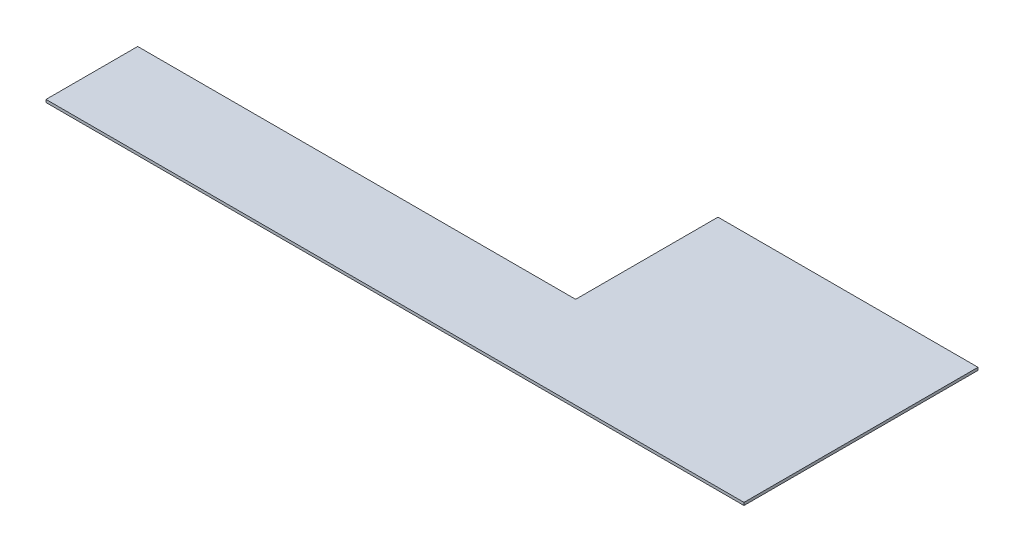
from build123d import *

# Parameters (mm, degrees)
BOSS_EXTRUDE1_DEPTH = 6.35


with BuildPart() as part:
    # Sketch1 → Boss-Extrude1 (new body)
    with BuildSketch(Plane(origin=(0, 0, 0), x_dir=(1, 0, 0), z_dir=(0, 1, 0))):
        Polygon((-1016, 0), (0, 0), (0, 330.2), (603.25, 330.2), (603.25, -212.725), (-1016, -212.725), align=None)
    extrude(amount=BOSS_EXTRUDE1_DEPTH)


solid = part.part
